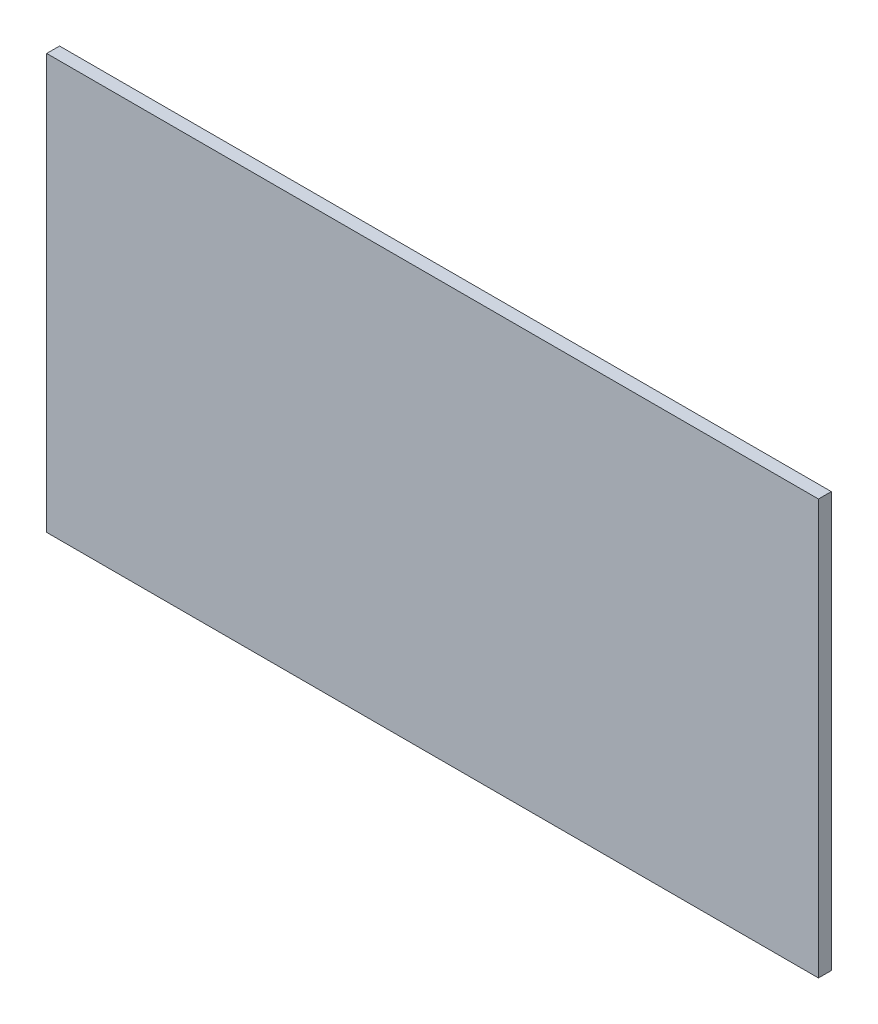
from build123d import *

# Parameters (mm, degrees)
CROQUIS1_W              = 1200
CROQUIS1_H              = 645
SALIENTE_EXTRUIR1_DEPTH = 20


with BuildPart() as part:
    # Croquis1 → Saliente-Extruir1 (new body)
    with BuildSketch(Plane.XY):
        with Locations((528.731355179, -300.106117021)):
            Rectangle(CROQUIS1_W, CROQUIS1_H)
    extrude(amount=SALIENTE_EXTRUIR1_DEPTH)


solid = part.part
